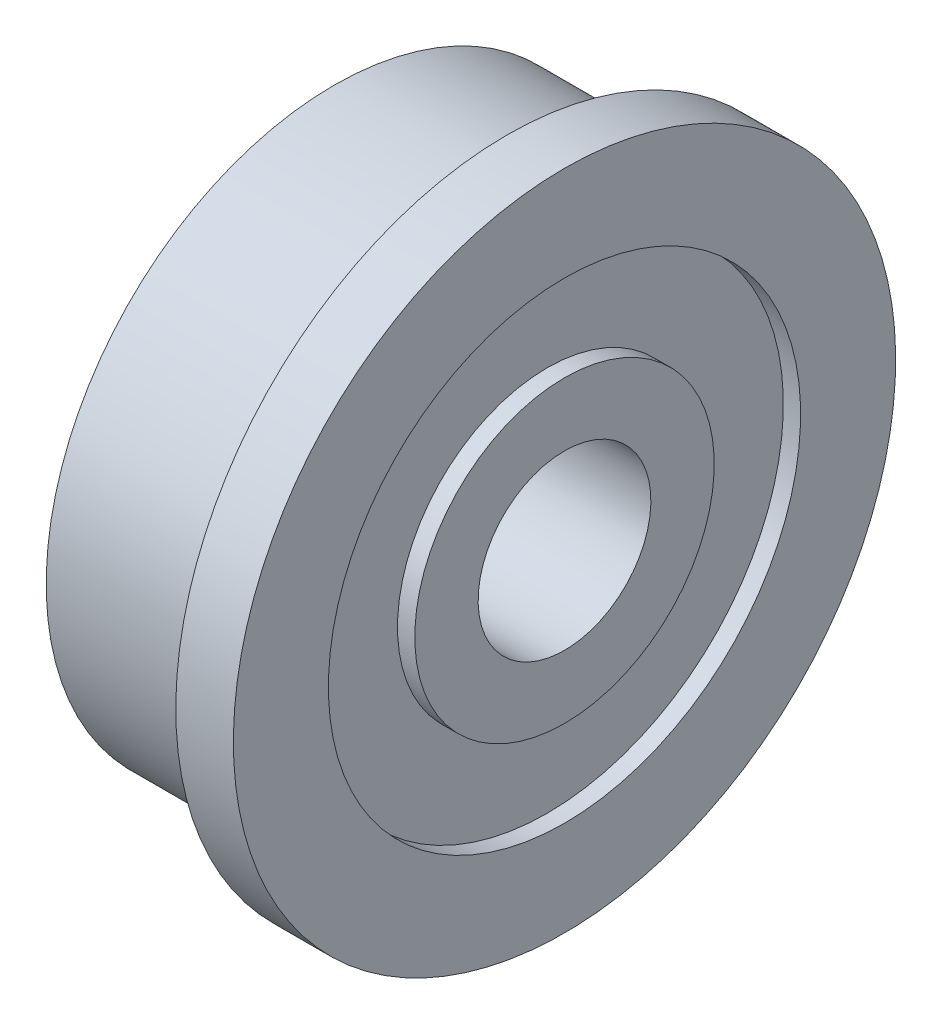
from build123d import *


with BuildPart() as part:
    # Sketch1 → Revolve1 (revolve)
    with BuildSketch(Plane.XY):
        Polygon((2, 1.5), (-2, 1.5), (-2, 2.6), (-1.7, 2.6), (-1.7, 4.1), (-2, 4.1), (-2, 5), (1, 5), (1, 5.75), (2, 5.75), (2, 4.1), (1.7, 4.1), (1.7, 2.6), (2, 2.6), align=None)
    revolve(axis=Axis((0, 0, 0), (-1, 0, 0)))


solid = part.part
